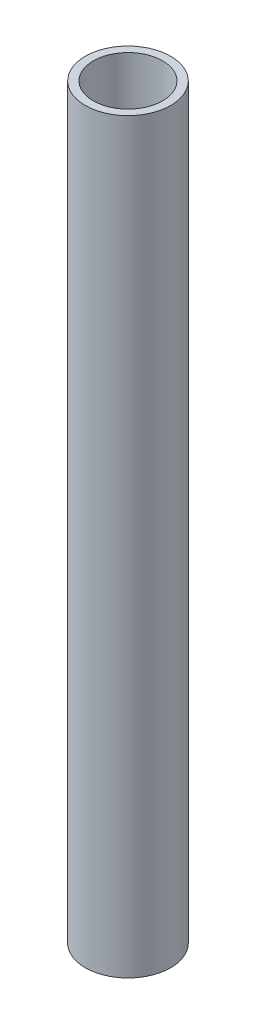
from build123d import *

# Parameters (mm, degrees)
SKETCH1_R           = 8
SKETCH1_R_2         = 6.5
BOSS_EXTRUDE1_DEPTH = 140


with BuildPart() as part:
    # Sketch1 → Boss-Extrude1 (new body)
    with BuildSketch(Plane(origin=(0, 0, 0), x_dir=(1, 0, 0), z_dir=(0, 1, 0))):
        Circle(SKETCH1_R)
        Circle(SKETCH1_R_2, mode=Mode.SUBTRACT)
    extrude(amount=BOSS_EXTRUDE1_DEPTH)


solid = part.part
